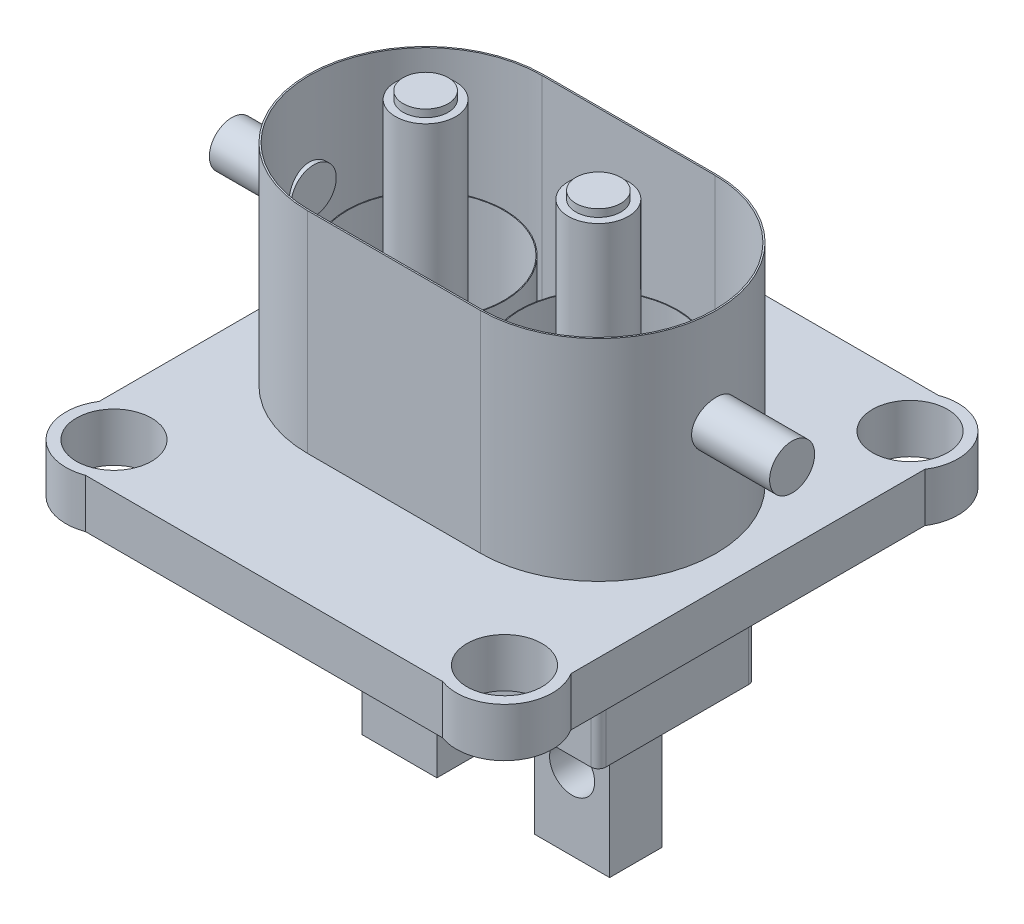
from build123d import *

# Parameters (mm, degrees)
DODANIE_WYCI_GNI_CIE1_DEPTH      = 6.5
SZKIC2_R                         = 6.4
DODANIE_WYCI_GNI_CIE2_DEPTH      = 6.5
SZKIC3_R                         = 5
WYTNIJ_WYCI_GNI_CIE4_DEPTH       = 6.5
SZKIC4_R                         = 10.5
SZKIC4_R_2                       = 10.4
DODANIE_WYCI_GNI_CIE3_DEPTH      = 15
DODANIE_WYCI_GNI_CIE4_DEPTH      = 16
SZKIC6_W                         = 10
SZKIC6_H                         = 7
DODANIE_WYCI_GNI_CIE5_DEPTH      = 34.5
SZKIC7_R                         = 4
DODANIE_WYCI_GNI_CIE6_DEPTH      = 33
SZKIC8_R                         = 3
DODANIE_WYCI_GNI_CIE7_DEPTH      = 1
SZKIC9_R                         = 3
DODANIE_WYCI_GNI_CIE8_DEPTH      = 5.9
DODANIE_WYCI_GNI_CIE8_DEPTH_BACK = 5
SZKIC10_R                        = 3
DODANIE_WYCI_GNI_CIE9_DEPTH      = 5.9
DODANIE_WYCI_GNI_CIE9_DEPTH_BACK = 5
DODANIE_WYCI_GNI_CIE10_DEPTH     = 28
SZKIC12_R                        = 3
WYTNIJ_WYCI_GNI_CIE5_DEPTH       = 7


with BuildPart() as part:
    # Szkic1 → Dodanie-wyciągnięcie1 (new body)
    with BuildSketch(Plane(origin=(0, 0, 0), x_dir=(1, 0, 0), z_dir=(0, 1, 0))):
        with BuildLine():
            Line((-49.920411058, 35.319148676), (-49.920411058, -21.880851324))
            ThreePointArc((-49.920411058, -21.880851324), (-48.631680895, -24.992121161), (-45.520411058, -26.280851324))
            Line((-45.520411058, -26.280851324), (8.479588942, -26.280851324))
            ThreePointArc((8.479588942, -26.280851324), (11.590858779, -24.992121161), (12.879588942, -21.880851324))
            Line((12.879588942, -21.880851324), (12.879588942, 35.319148676))
            ThreePointArc((12.879588942, 35.319148676), (11.590858779, 38.430418513), (8.479588942, 39.719148676))
            Line((8.479588942, 39.719148676), (-45.520411058, 39.719148676))
            ThreePointArc((-45.520411058, 39.719148676), (-48.631680895, 38.430418513), (-49.920411058, 35.319148676))
        make_face()
    extrude(amount=DODANIE_WYCI_GNI_CIE1_DEPTH)

    # Szkic2 → Dodanie-wyciągnięcie2 (add)
    with BuildSketch(Plane(origin=(0, 0, 0), x_dir=(1, 0, 0), z_dir=(0, 1, 0))):
        with Locations((-44.520411058, 33.719148676)):
            Circle(SZKIC2_R)
        with Locations((-44.520411058, -20.280851324)):
            Circle(SZKIC2_R)
        with Locations((7.479588942, -20.280851324)):
            Circle(SZKIC2_R)
        with Locations((7.479588942, 33.719148676)):
            Circle(SZKIC2_R)
    extrude(amount=DODANIE_WYCI_GNI_CIE2_DEPTH)

    # Szkic3 → Wytnij-wyciągnięcie4 (cut)
    with BuildSketch(Plane(origin=(0, 6.5, 0), x_dir=(1, 0, 0), z_dir=(0, 1, 0))):
        with Locations((7.479588942, 33.719148676)):
            Circle(SZKIC3_R)
        with Locations((-44.520411058, 33.719148676)):
            Circle(SZKIC3_R)
        with Locations((7.479588942, -20.280851324)):
            Circle(SZKIC3_R)
        with Locations((-44.520411058, -20.280851324)):
            Circle(SZKIC3_R)
    extrude(amount=-WYTNIJ_WYCI_GNI_CIE4_DEPTH, mode=Mode.SUBTRACT)

    # Szkic4 → Dodanie-wyciągnięcie3 (add)
    with BuildSketch(Plane(origin=(0, 6.5, 0), x_dir=(1, 0, 0), z_dir=(0, 1, 0))):
        with Locations((-30.020411058, 6.719148676)):
            Circle(SZKIC4_R)
        with Locations((-30.020411058, 6.719148676)):
            Circle(SZKIC4_R_2, mode=Mode.SUBTRACT)
        with Locations((-7.020411058, 6.719148676)):
            Circle(SZKIC4_R)
        with Locations((-7.020411058, 6.719148676)):
            Circle(SZKIC4_R_2, mode=Mode.SUBTRACT)
    extrude(amount=DODANIE_WYCI_GNI_CIE3_DEPTH)

    # Szkic5 → Dodanie-wyciągnięcie4 (add)
    with BuildSketch(Plane(origin=(0, 0, 0), x_dir=(-1, 0, 0), z_dir=(0, -1, 0))):
        with BuildLine():
            Line((-3.479588942, -2.780851324), (-3.479588942, 16.219148676))
            ThreePointArc((-3.479588942, 16.219148676), (-3.186695723, 16.926255457), (-2.479588942, 17.219148676))
            Line((-2.479588942, 17.219148676), (39.520411058, 17.219148676))
            ThreePointArc((39.520411058, 17.219148676), (40.227517839, 16.926255457), (40.520411058, 16.219148676))
            Line((40.520411058, 16.219148676), (40.520411058, -2.780851324))
            ThreePointArc((40.520411058, -2.780851324), (40.227517839, -3.487958105), (39.520411058, -3.780851324))
            Line((39.520411058, -3.780851324), (-2.479588942, -3.780851324))
            ThreePointArc((-2.479588942, -3.780851324), (-3.186695723, -3.487958105), (-3.479588942, -2.780851324))
        make_face()
    extrude(amount=DODANIE_WYCI_GNI_CIE4_DEPTH)

    # Szkic6 → Dodanie-wyciągnięcie5 (add)
    with BuildSketch(Plane(origin=(0, 0, 0), x_dir=(-1, 0, 0), z_dir=(0, -1, 0))):
        with Locations((30.020411058, 6.719148676)):
            Rectangle(SZKIC6_W, SZKIC6_H)
        with Locations((7.020411058, 6.719148676)):
            Rectangle(SZKIC6_W, SZKIC6_H)
    extrude(amount=DODANIE_WYCI_GNI_CIE5_DEPTH)

    # Szkic7 → Dodanie-wyciągnięcie6 (add)
    with BuildSketch(Plane(origin=(0, 6.5, 0), x_dir=(1, 0, 0), z_dir=(0, 1, 0))):
        with Locations((-30.020411058, 6.719148676)):
            Circle(SZKIC7_R)
        with Locations((-7.020411058, 6.719148676)):
            Circle(SZKIC7_R)
    extrude(amount=DODANIE_WYCI_GNI_CIE6_DEPTH)

    # Szkic8 → Dodanie-wyciągnięcie7 (add)
    with BuildSketch(Plane(origin=(0, 39.5, 0), x_dir=(1, 0, 0), z_dir=(0, 1, 0))):
        with Locations((-30.020411058, 6.719148676)):
            Circle(SZKIC8_R)
        with Locations((-7.020411058, 6.719148676)):
            Circle(SZKIC8_R)
    extrude(amount=DODANIE_WYCI_GNI_CIE7_DEPTH)



with BuildPart() as body_2:
    # Szkic9 → Dodanie-wyciągnięcie8 (new body, two sides)
    with BuildSketch(Plane.ZY.offset(49.920411058)) as dodanie_wyci_gni_cie8_sk:
        with Locations((-6.719148676, 21.5)):
            Circle(SZKIC9_R)
    extrude(amount=DODANIE_WYCI_GNI_CIE8_DEPTH)
    extrude(dodanie_wyci_gni_cie8_sk.sketch, amount=-DODANIE_WYCI_GNI_CIE8_DEPTH_BACK)


with BuildPart() as body_3:
    # Szkic10 → Dodanie-wyciągnięcie9 (new body, two sides)
    with BuildSketch(Plane(origin=(12.879588942, 0, 0), x_dir=(0, 0, -1), z_dir=(1, 0, 0))) as dodanie_wyci_gni_cie9_sk:
        with Locations((6.719148676, 21.5)):
            Circle(SZKIC10_R)
    extrude(amount=DODANIE_WYCI_GNI_CIE9_DEPTH)
    extrude(dodanie_wyci_gni_cie9_sk.sketch, amount=-DODANIE_WYCI_GNI_CIE9_DEPTH_BACK)


with BuildPart() as part_1:
    add(part.part)

    add(body_2.part)  # Dodanie-wyciągnięcie10 merges body 2

    add(body_3.part)  # Dodanie-wyciągnięcie10 merges body 3
    # Szkic11 → Dodanie-wyciągnięcie10 (add)
    with BuildSketch(Plane(origin=(0, 6.5, 0), x_dir=(1, 0, 0), z_dir=(0, 1, 0))):
        with BuildLine():
            Line((-7.020411058, 22.419148676), (-30.020411058, 22.419148676))
            ThreePointArc((-30.020411058, 22.419148676), (-45.720411058, 6.719148676), (-30.020411058, -8.980851324))
            Line((-30.020411058, -8.980851324), (-7.020411058, -8.980851324))
            ThreePointArc((-7.020411058, -8.980851324), (8.679588942, 6.719148676), (-7.020411058, 22.419148676))
        make_face()
        with BuildLine():
            Line((-7.020411058, 22.219148676), (-30.020411058, 22.219148676))
            ThreePointArc((-30.020411058, 22.219148676), (-45.520411058, 6.719148676), (-30.020411058, -8.780851324))
            Line((-30.020411058, -8.780851324), (-7.020411058, -8.780851324))
            ThreePointArc((-7.020411058, -8.780851324), (8.479588942, 6.719148676), (-7.020411058, 22.219148676))
        make_face(mode=Mode.SUBTRACT)
    extrude(amount=DODANIE_WYCI_GNI_CIE10_DEPTH)

    # Szkic12 → Wytnij-wyciągnięcie5 (cut)
    with BuildSketch(Plane.XY.offset(-3.219148676)):
        with Locations((-7.020411058, -24.5)):
            Circle(SZKIC12_R)
        with Locations((-30.020411058, -24.5)):
            Circle(SZKIC12_R)
    extrude(amount=-WYTNIJ_WYCI_GNI_CIE5_DEPTH, mode=Mode.SUBTRACT)


solid = part_1.part
